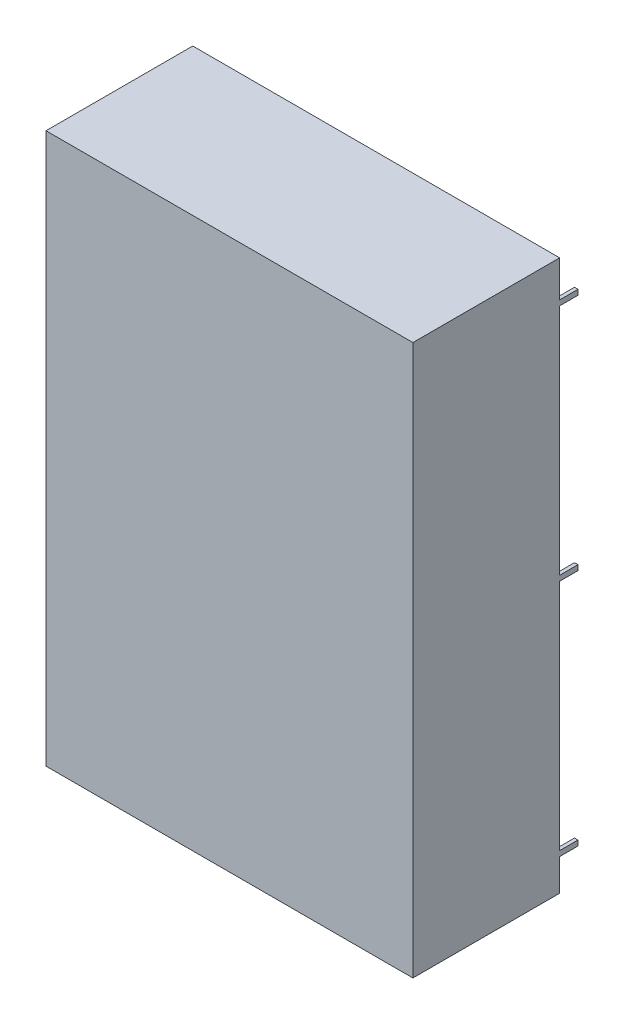
from build123d import *

# Parameters (mm, degrees)
ESQUISSE1_W                          = 200
ESQUISSE1_H                          = 300
BOSS_EXTRU_1_DEPTH                   = 80
COQUE1_T                             = -4
ESQUISSE3_W                          = 196.2
ESQUISSE3_H                          = 296.2
ENL_V_MAT_EXTRU_2_DEPTH              = 4.1
ESQUISSE4_R                          = 9
BOSS_EXTRU_2_DEPTH                   = 67.9
ESQUISSE5_R                          = 2.5
ENL_V_MAT_EXTRU_3_DEPTH              = 30
ESQUISSE4_4_R                        = 9
BOSS_EXTRU_3_DEPTH                   = 15
ESQUISSE6_R                          = 2.5
ENL_V_MAT_EXTRU_6_DEPTH              = 10
ESQUISSE8_R                          = 9
BOSS_EXTRU_5_DEPTH                   = 68
ESQUISSE9_R                          = 2.5
ENL_V_MAT_EXTRU_8_DEPTH              = 30
ESQUISSE10_W                         = 1.9
ESQUISSE10_H                         = 2.840533171
BOSS_EXTRU_6_DEPTH                   = 10
R_P_TITION_LIN_AIRE1_COUNT           = 2
R_P_TITION_LIN_AIRE1_PITCH           = 198.1
R_P_TITION_LIN_AIRE2_COPY_1_SKETCH_W = 1.9
R_P_TITION_LIN_AIRE2_COPY_1_SKETCH_H = 2.840533171
R_P_TITION_LIN_AIRE2_COPY_1_DEPTH    = 10
R_P_TITION_LIN_AIRE2_COPY_2_SKETCH_W = 1.9
R_P_TITION_LIN_AIRE2_COPY_2_SKETCH_H = 2.840533171
R_P_TITION_LIN_AIRE2_COPY_2_DEPTH    = 10
R_P_TITION_LIN_AIRE2_COPY_3_SKETCH_W = 1.9
R_P_TITION_LIN_AIRE2_COPY_3_SKETCH_H = 2.840533171
R_P_TITION_LIN_AIRE2_COPY_3_DEPTH    = 10
R_P_TITION_LIN_AIRE2_COPY_4_SKETCH_W = 1.9
R_P_TITION_LIN_AIRE2_COPY_4_SKETCH_H = 2.840533171
R_P_TITION_LIN_AIRE2_COPY_4_DEPTH    = 10


with BuildPart() as part:
    # Esquisse1 → Boss.-Extru.1 (new body)
    with BuildSketch(Plane.XY):
        with Locations((43.373964051, -118.711656442)):
            Rectangle(ESQUISSE1_W, ESQUISSE1_H)
    extrude(amount=BOSS_EXTRU_1_DEPTH)

    # Coque1
    coque1_openings = [part.faces().sort_by_distance(p)[0] for p in [
        (43.373964051, -118.711656442, 0),
    ]]
    offset(amount=COQUE1_T, openings=coque1_openings, kind=Kind.INTERSECTION)

    # Esquisse3 → Enlèv. mat.-Extru.2 (cut)
    with BuildSketch(Plane(origin=(0, 0, 0), x_dir=(-1, 0, 0), z_dir=(0, 0, -1))):
        with Locations((-43.373964051, -118.711656442)):
            Rectangle(ESQUISSE3_W, ESQUISSE3_H)
    extrude(amount=-ENL_V_MAT_EXTRU_2_DEPTH, mode=Mode.SUBTRACT)

    # Esquisse4 → Boss.-Extru.2 (add)
    with BuildSketch(Plane(origin=(0, 0, 76), x_dir=(-1, 0, 0), z_dir=(0, 0, -1))):
        with Locations((-119.373964051, 7.288343558)):
            Circle(ESQUISSE4_R)
    extrude(amount=BOSS_EXTRU_2_DEPTH)

    # Esquisse5 → Enlèv. mat.-Extru.3 (cut)
    with BuildSketch(Plane(origin=(0, 0, 8.1), x_dir=(-1, 0, 0), z_dir=(0, 0, -1))):
        with Locations((-119.373964051, 7.288343558)):
            Circle(ESQUISSE5_R)
    extrude(amount=-ENL_V_MAT_EXTRU_3_DEPTH, mode=Mode.SUBTRACT)

    # Esquisse4_4 → Boss.-Extru.3 (add)
    with BuildSketch(Plane(origin=(0, 0, 76), x_dir=(-1, 0, 0), z_dir=(0, 0, -1))):
        with Locations((15.126035949, -185.711656442)):
            Circle(ESQUISSE4_4_R)
        with Locations((-101.873964051, -185.711656442)):
            Circle(ESQUISSE4_4_R)
        with Locations((-101.873964051, -51.711656442)):
            Circle(ESQUISSE4_4_R)
        with Locations((15.126035949, -51.711656442)):
            Circle(ESQUISSE4_4_R)
    extrude(amount=BOSS_EXTRU_3_DEPTH)

    # Esquisse6 → Enlèv. mat.-Extru.6 (cut)
    with BuildSketch(Plane(origin=(0, 0, 61), x_dir=(-1, 0, 0), z_dir=(0, 0, -1))):
        with Locations((-101.873964051, -51.711656442)):
            Circle(ESQUISSE6_R)
        with Locations((15.126035949, -51.711656442)):
            Circle(ESQUISSE6_R)
        with Locations((-101.873964051, -185.711656442)):
            Circle(ESQUISSE6_R)
        with Locations((15.126035949, -185.711656442)):
            Circle(ESQUISSE6_R)
    extrude(amount=-ENL_V_MAT_EXTRU_6_DEPTH, mode=Mode.SUBTRACT)

    # Esquisse8 → Boss.-Extru.5 (add)
    with BuildSketch(Plane(origin=(0, 0, 76), x_dir=(-1, 0, 0), z_dir=(0, 0, -1))):
        with Locations((32.626035949, 7.288343558)):
            Circle(ESQUISSE8_R)
        with Locations((32.626035949, -244.711656442)):
            Circle(ESQUISSE8_R)
        with Locations((-119.373964051, -244.711656442)):
            Circle(ESQUISSE8_R)
    extrude(amount=BOSS_EXTRU_5_DEPTH)

    # Esquisse9 → Enlèv. mat.-Extru.8 (cut)
    with BuildSketch(Plane(origin=(0, 0, 8), x_dir=(-1, 0, 0), z_dir=(0, 0, -1))):
        with Locations((32.626035949, 7.288343558)):
            Circle(ESQUISSE9_R)
        with Locations((32.626035949, -244.711656442)):
            Circle(ESQUISSE9_R)
        with Locations((-119.373964051, -244.711656442)):
            Circle(ESQUISSE9_R)
    extrude(amount=-ENL_V_MAT_EXTRU_8_DEPTH, mode=Mode.SUBTRACT)

    # Esquisse10 → Boss.-Extru.6 (add)
    with BuildSketch(Plane(origin=(0, 0, 0), x_dir=(-1, 0, 0), z_dir=(0, 0, -1))):
        with Locations((-142.423964051, -249.983146828)):
            Rectangle(ESQUISSE10_W, ESQUISSE10_H)
    boss_extru_6 = extrude(amount=BOSS_EXTRU_6_DEPTH)

    # Répétition linéaire1: Boss.-Extru.6 ×2
    with Locations(*[(-i * R_P_TITION_LIN_AIRE1_PITCH, 0, 0) for i in range(1, R_P_TITION_LIN_AIRE1_COUNT)]):
        add(boss_extru_6)

    # Répétition linéaire2 copy 1 sketch → Répétition linéaire2 copy 1 (add)
    with BuildSketch(Plane(origin=(-198.1, 130, 0), x_dir=(-1, 0, 0), z_dir=(0, 0, -1))):
        with Locations((-142.423964051, -249.983146828)):
            Rectangle(R_P_TITION_LIN_AIRE2_COPY_1_SKETCH_W, R_P_TITION_LIN_AIRE2_COPY_1_SKETCH_H)
    extrude(amount=R_P_TITION_LIN_AIRE2_COPY_1_DEPTH)

    # Répétition linéaire2 copy 2 sketch → Répétition linéaire2 copy 2 (add)
    with BuildSketch(Plane(origin=(-198.1, 260, 0), x_dir=(-1, 0, 0), z_dir=(0, 0, -1))):
        with Locations((-142.423964051, -249.983146828)):
            Rectangle(R_P_TITION_LIN_AIRE2_COPY_2_SKETCH_W, R_P_TITION_LIN_AIRE2_COPY_2_SKETCH_H)
    extrude(amount=R_P_TITION_LIN_AIRE2_COPY_2_DEPTH)

    # Répétition linéaire2 copy 3 sketch → Répétition linéaire2 copy 3 (add)
    with BuildSketch(Plane(origin=(0, 130, 0), x_dir=(-1, 0, 0), z_dir=(0, 0, -1))):
        with Locations((-142.423964051, -249.983146828)):
            Rectangle(R_P_TITION_LIN_AIRE2_COPY_3_SKETCH_W, R_P_TITION_LIN_AIRE2_COPY_3_SKETCH_H)
    extrude(amount=R_P_TITION_LIN_AIRE2_COPY_3_DEPTH)

    # Répétition linéaire2 copy 4 sketch → Répétition linéaire2 copy 4 (add)
    with BuildSketch(Plane(origin=(0, 260, 0), x_dir=(-1, 0, 0), z_dir=(0, 0, -1))):
        with Locations((-142.423964051, -249.983146828)):
            Rectangle(R_P_TITION_LIN_AIRE2_COPY_4_SKETCH_W, R_P_TITION_LIN_AIRE2_COPY_4_SKETCH_H)
    extrude(amount=R_P_TITION_LIN_AIRE2_COPY_4_DEPTH)


solid = part.part
